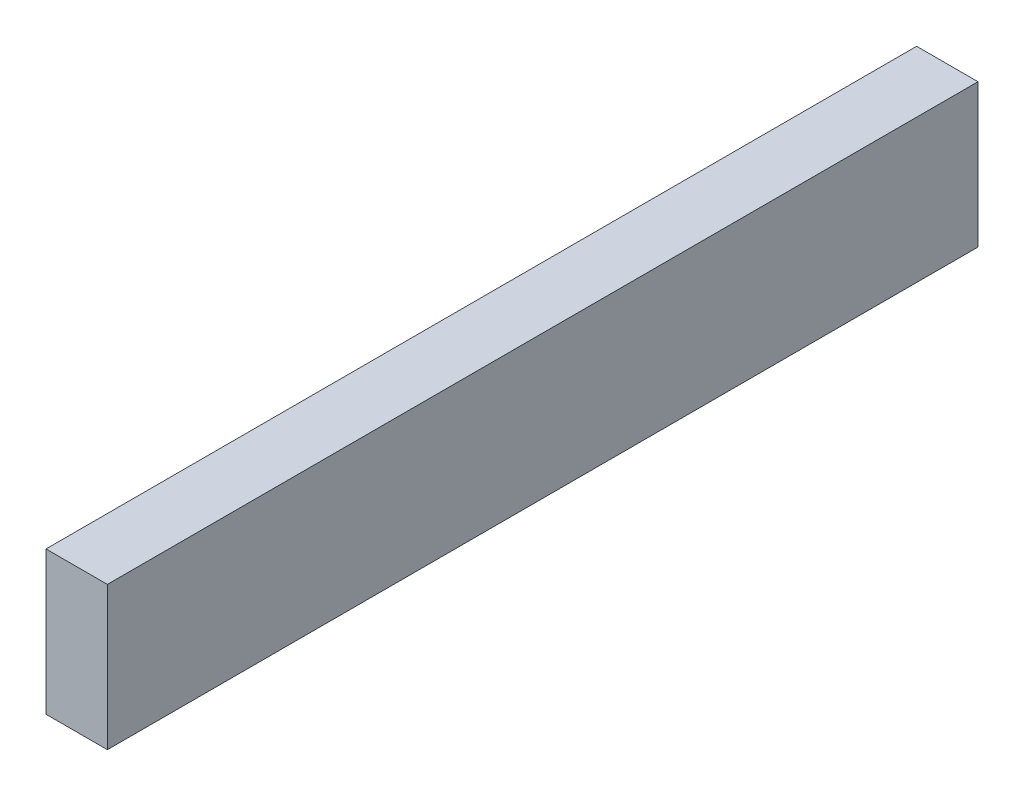
from build123d import *

# Parameters (mm, degrees)
SKETCH1_W           = 38.1
SKETCH1_H           = 88.9
BOSS_EXTRUDE1_DEPTH = 540.54375


with BuildPart() as part:
    # Sketch1 → Boss-Extrude1 (new body)
    with BuildSketch(Plane.XY):
        with Locations((16.669985729, -16.679464952)):
            Rectangle(SKETCH1_W, SKETCH1_H)
    extrude(amount=BOSS_EXTRUDE1_DEPTH)


solid = part.part
